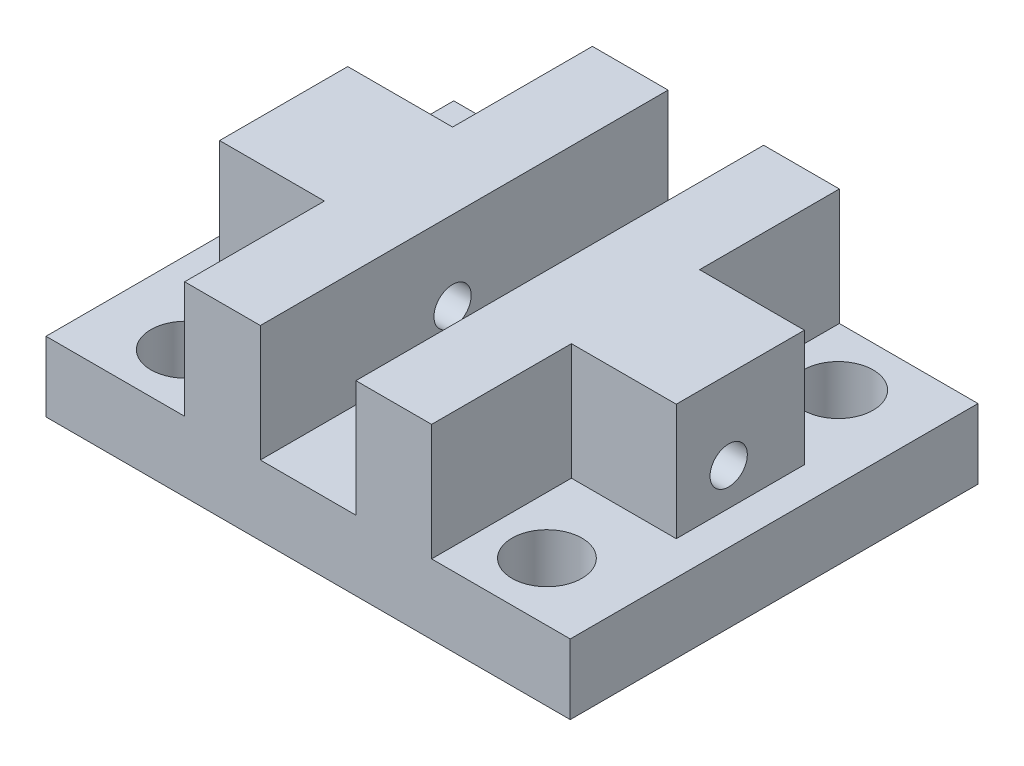
from build123d import *

# Parameters (mm, degrees)
ESQUISSE1_W                  = 45
ESQUISSE1_H                  = 35
BOSS_EXTRU_1_DEPTH           = 6
ESQUISSE2_R                  = 3
ENL_V_MAT_EXTRU_1_DEPTH      = 7
ESQUISSE3_W                  = 8.2
ESQUISSE3_H                  = 16.2
ENL_V_MAT_EXTRU_2_DEPTH      = 7
ESQUISSE4_W                  = 35
ESQUISSE4_H                  = 10
BOSS_EXTRU_2_DEPTH           = 6.5
ESQUISSE5_W                  = 35
ESQUISSE5_H                  = 10
BOSS_EXTRU_3_DEPTH           = 6.5
ESQUISSE7_W                  = 11
ESQUISSE7_H                  = 10
BOSS_EXTRU_4_DEPTH           = 9
ESQUISSE8_W                  = 11
ESQUISSE8_H                  = 10
BOSS_EXTRU_5_DEPTH           = 9
ESQUISSE6_R                  = 1.6
ENL_V_MAT_EXTRU_3_DEPTH      = 12.9
ENL_V_MAT_EXTRU_3_DEPTH_BACK = 34.1


with BuildPart() as part:
    # Esquisse1 → Boss.-Extru.1 (new body)
    with BuildSketch(Plane(origin=(0, 0, 0), x_dir=(1, 0, 0), z_dir=(0, 1, 0))):
        with Locations((0, 1)):
            Rectangle(ESQUISSE1_W, ESQUISSE1_H)
    extrude(amount=BOSS_EXTRU_1_DEPTH)

    # Esquisse2 → Enlèv. mat.-Extru.1 (cut, through all)
    with BuildSketch(Plane(origin=(0, 6, 0), x_dir=(1, 0, 0), z_dir=(0, 1, 0))):
        with Locations((-15.5, 13.5)):
            Circle(ESQUISSE2_R)
        with Locations((-15.5, -11.5)):
            Circle(ESQUISSE2_R)
        with Locations((15.5, -11.5)):
            Circle(ESQUISSE2_R)
        with Locations((15.5, 13.5)):
            Circle(ESQUISSE2_R)
    extrude(amount=-ENL_V_MAT_EXTRU_1_DEPTH, mode=Mode.SUBTRACT)

    # Esquisse3 → Enlèv. mat.-Extru.2 (cut, through all)
    with BuildSketch(Plane(origin=(0, 6, 0), x_dir=(1, 0, 0), z_dir=(0, 1, 0))):
        Rectangle(ESQUISSE3_W, ESQUISSE3_H)
    extrude(amount=-ENL_V_MAT_EXTRU_2_DEPTH, mode=Mode.SUBTRACT)

    # Esquisse4 → Boss.-Extru.2 (add)
    with BuildSketch(Plane(origin=(-4.1, 0, 0), x_dir=(0, 0, -1), z_dir=(1, 0, 0))):
        with Locations((1, 11)):
            Rectangle(ESQUISSE4_W, ESQUISSE4_H)
    extrude(amount=-BOSS_EXTRU_2_DEPTH)

    # Esquisse5 → Boss.-Extru.3 (add)
    with BuildSketch(Plane(origin=(4.1, 0, -4), x_dir=(0, 0, 1), z_dir=(-1, 0, 0))):
        with Locations((3, 11)):
            Rectangle(ESQUISSE5_W, ESQUISSE5_H)
    extrude(amount=-BOSS_EXTRU_3_DEPTH)

    # Esquisse7 → Boss.-Extru.4 (add)
    with BuildSketch(Plane(origin=(10.6, 0, 0), x_dir=(0, 0, -1), z_dir=(1, 0, 0))):
        with Locations((1, 11)):
            Rectangle(ESQUISSE7_W, ESQUISSE7_H)
    extrude(amount=BOSS_EXTRU_4_DEPTH)

    # Esquisse8 → Boss.-Extru.5 (add)
    with BuildSketch(Plane(origin=(-10.6, 0, -10.5), x_dir=(0, 0, -1), z_dir=(1, 0, 0))):
        with Locations((-9.5, 11)):
            Rectangle(ESQUISSE8_W, ESQUISSE8_H)
    extrude(amount=-BOSS_EXTRU_5_DEPTH)

    # Esquisse6 → Enlèv. mat.-Extru.3 (cut, two sides)
    with BuildSketch(Plane(origin=(10.6, 0, 0), x_dir=(0, 0, -1), z_dir=(1, 0, 0))) as enl_v_mat_extru_3_sk:
        with Locations((0, 9.2)):
            Circle(ESQUISSE6_R)
    extrude(amount=ENL_V_MAT_EXTRU_3_DEPTH, mode=Mode.SUBTRACT)
    extrude(enl_v_mat_extru_3_sk.sketch, amount=-ENL_V_MAT_EXTRU_3_DEPTH_BACK, mode=Mode.SUBTRACT)


solid = part.part
